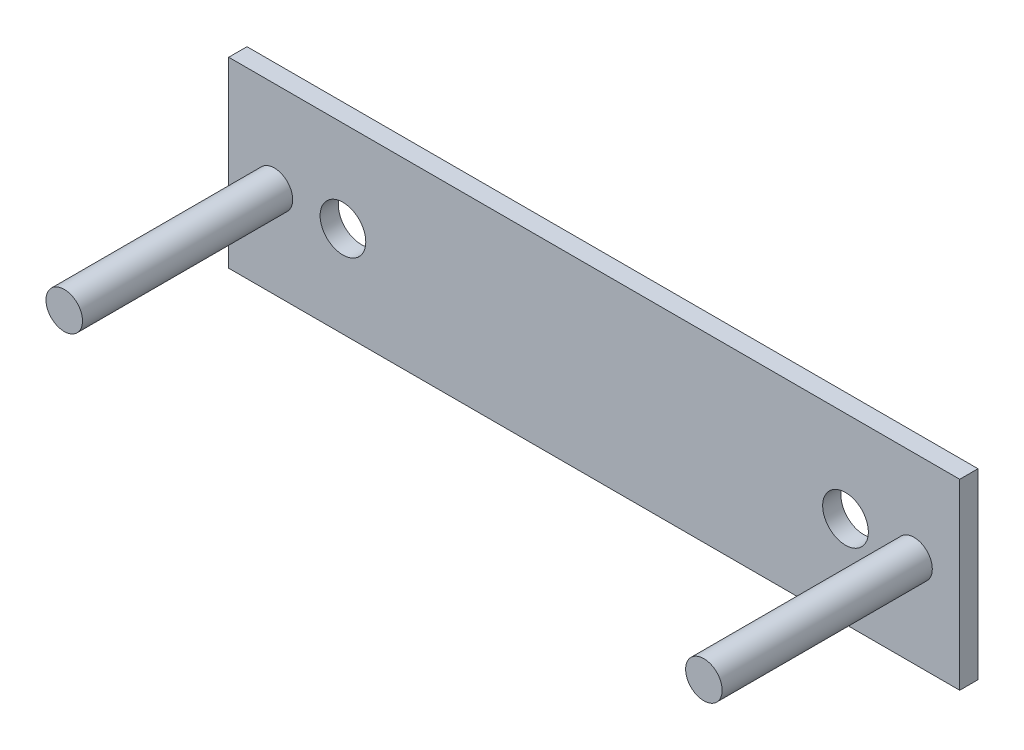
from build123d import *

# Parameters (mm, degrees)
SKETCH1_W           = 80
SKETCH1_H           = 20
SKETCH1_R           = 2.5
BOSS_EXTRUDE1_DEPTH = 2
SKETCH2_R           = 2
BOSS_EXTRUDE2_DEPTH = 23


with BuildPart() as part:
    # Sketch1 → Boss-Extrude1 (new body)
    with BuildSketch(Plane.XY):
        with Locations((-9.925787146, -16.395190745)):
            Rectangle(SKETCH1_W, SKETCH1_H)
        with Locations((-37.425787146, -16.395190745)):
            Circle(SKETCH1_R, mode=Mode.SUBTRACT)
        with Locations((17.574212854, -16.395190745)):
            Circle(SKETCH1_R, mode=Mode.SUBTRACT)
    extrude(amount=BOSS_EXTRUDE1_DEPTH)

    # Sketch2 → Boss-Extrude2 (add)
    with BuildSketch(Plane.XY.offset(2)):
        with Locations((25.074212854, -16.395190745)):
            Circle(SKETCH2_R)
        with Locations((-44.925787146, -16.395190745)):
            Circle(SKETCH2_R)
    extrude(amount=BOSS_EXTRUDE2_DEPTH)


solid = part.part
